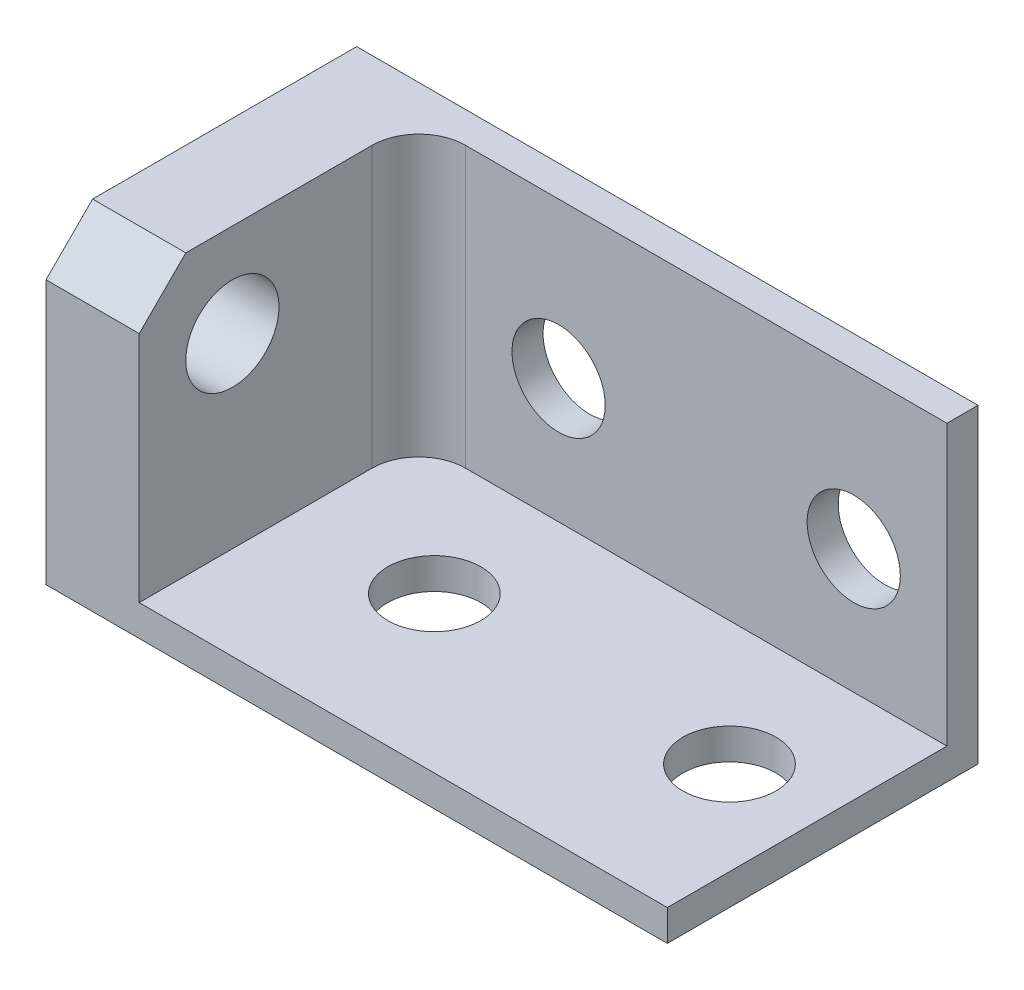
from build123d import *

# Parameters (mm, degrees)
ESQUISSE1_W             = 40
ESQUISSE1_H             = 20
BOSS_EXTRU_1_DEPTH      = 2
ESQUISSE2_W             = 40
ESQUISSE2_H             = 2
BOSS_EXTRU_2_DEPTH      = 18
ESQUISSE3_R             = 3
ENL_V_MAT_EXTRU_1_DEPTH = 18
ESQUISSE4_R             = 3
ENL_V_MAT_EXTRU_2_DEPTH = 18
ESQUISSE5_R             = 3
ENL_V_MAT_EXTRU_3_DEPTH = 18
ESQUISSE6_R             = 3
ENL_V_MAT_EXTRU_4_DEPTH = 18
ESQUISSE7_W             = 6
ESQUISSE7_H             = 18
BOSS_EXTRU_3_DEPTH      = 18
ESQUISSE8_R             = 3
ENL_V_MAT_EXTRU_5_DEPTH = 18
CHANFREIN1_SIZE         = 3
CONG_1_R                = 3


with BuildPart() as part:
    # Esquisse1 → Boss.-Extru.1 (new body)
    with BuildSketch(Plane.XY):
        with Locations((-20, 10)):
            Rectangle(ESQUISSE1_W, ESQUISSE1_H)
    extrude(amount=BOSS_EXTRU_1_DEPTH)

    # Esquisse2 → Boss.-Extru.2 (add)
    with BuildSketch(Plane.XY.offset(2)):
        with Locations((-20, 1)):
            Rectangle(ESQUISSE2_W, ESQUISSE2_H)
    extrude(amount=BOSS_EXTRU_2_DEPTH)

    # Esquisse3 → Enlèv. mat.-Extru.1 (cut)
    with BuildSketch(Plane.XY.offset(2)):
        with Locations((-6, 10)):
            Circle(ESQUISSE3_R)
    extrude(amount=-ENL_V_MAT_EXTRU_1_DEPTH, mode=Mode.SUBTRACT)

    # Esquisse4 → Enlèv. mat.-Extru.2 (cut)
    with BuildSketch(Plane.XY.offset(2)):
        with Locations((-25, 10)):
            Circle(ESQUISSE4_R)
    extrude(amount=-ENL_V_MAT_EXTRU_2_DEPTH, mode=Mode.SUBTRACT)

    # Esquisse5 → Enlèv. mat.-Extru.3 (cut)
    with BuildSketch(Plane(origin=(0, 2, 0), x_dir=(1, 0, 0), z_dir=(0, 1, 0))):
        with Locations(Location((-6, -10, 0), (0, 0, 180))):  # turned: the seam where the file's is
            Circle(ESQUISSE5_R)
    extrude(amount=-ENL_V_MAT_EXTRU_3_DEPTH, mode=Mode.SUBTRACT)

    # Esquisse6 → Enlèv. mat.-Extru.4 (cut)
    with BuildSketch(Plane(origin=(0, 2, 0), x_dir=(1, 0, 0), z_dir=(0, 1, 0))):
        with Locations(Location((-25, -10, 0), (0, 0, 180))):  # turned: the seam where the file's is
            Circle(ESQUISSE6_R)
    extrude(amount=-ENL_V_MAT_EXTRU_4_DEPTH, mode=Mode.SUBTRACT)

    # Esquisse7 → Boss.-Extru.3 (add)
    with BuildSketch(Plane(origin=(0, 2, 0), x_dir=(1, 0, 0), z_dir=(0, 1, 0))):
        with Locations((-37, -11)):
            Rectangle(ESQUISSE7_W, ESQUISSE7_H)
    extrude(amount=BOSS_EXTRU_3_DEPTH)

    # Esquisse8 → Enlèv. mat.-Extru.5 (cut)
    with BuildSketch(Plane.ZY.offset(40)):
        with Locations((14, 14)):
            Circle(ESQUISSE8_R)
    extrude(amount=-ENL_V_MAT_EXTRU_5_DEPTH, mode=Mode.SUBTRACT)

    # Chanfrein1
    chanfrein1_edges = [part.edges().sort_by_distance(p)[0] for p in [
        (-37, 20, 20),
    ]]
    chamfer(chanfrein1_edges, length=CHANFREIN1_SIZE)

    # Congé1
    cong_1_edges = [part.edges().sort_by_distance(p)[0] for p in [
        (-34, 11, 2),
    ]]
    fillet(cong_1_edges, radius=CONG_1_R)


solid = part.part
